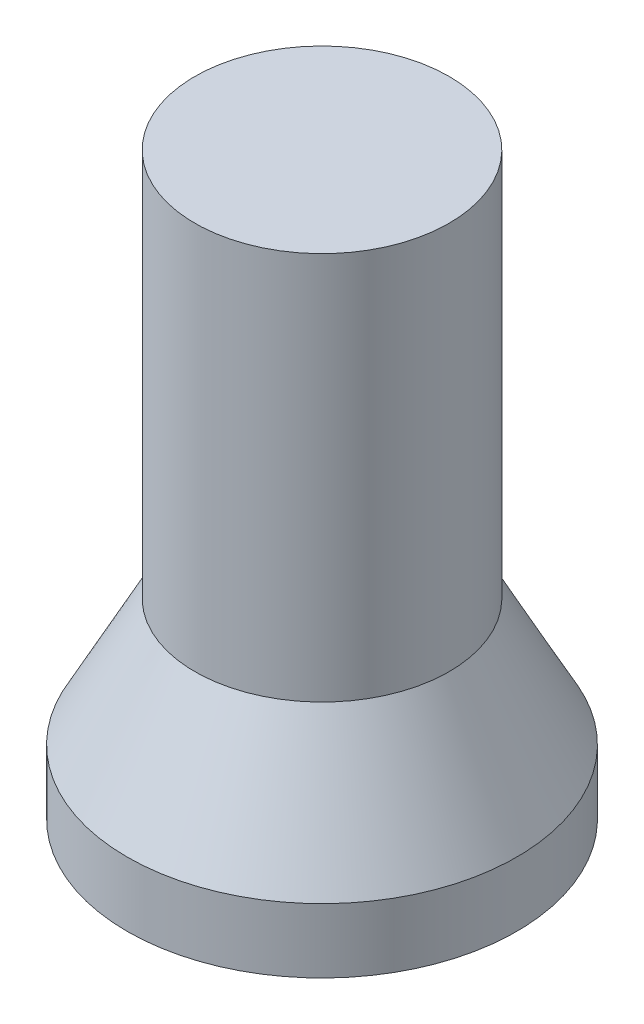
from build123d import *


with BuildPart() as part:
    # Sketch3 → Revolve3 (revolve)
    with BuildSketch(Plane(origin=(0, 0, 0), x_dir=(0, 0, -1), z_dir=(1, 0, 0))):
        Polygon((5.05, 0), (5.05, 2), (4.516666667, 3), (0, 3), (0, 18), (3.95, 18), (3.95, 5.9375), (6.05, 2), (6.05, 0), align=None)
    revolve(axis=Axis((0, -43.514912226, 0), (0, 1, 0)))


solid = part.part
